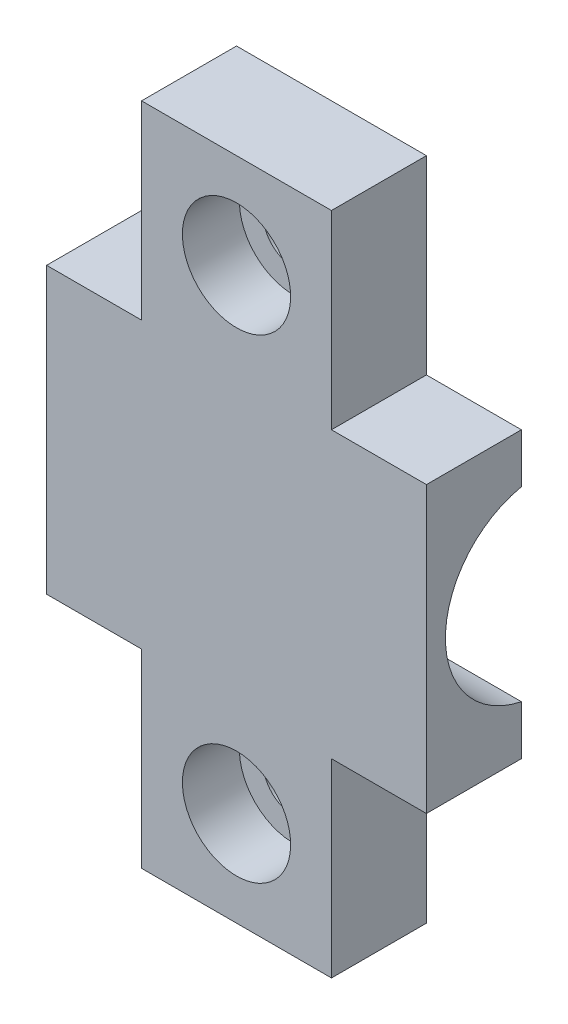
from build123d import *

# Parameters (mm, degrees)
BOSS_EXTRUDE1_DEPTH     = 20
CUT_EXTRUDE1_DEPTH      = 28.041634566
CUT_EXTRUDE1_DEPTH_BACK = 28.041634566
SKETCH2_W               = 5
SKETCH2_H               = 10
SKETCH2_R               = 1.6
CUT_EXTRUDE2_DEPTH      = 28.041634566
CUT_EXTRUDE2_DEPTH_BACK = 3
SKETCH2_3_R             = 2.85
SKETCH2_3_R_2           = 1.6


with BuildPart() as part:
    # Sketch1 → Boss-Extrude1 (new body)
    with BuildSketch(Plane.YZ):
        with BuildLine():
            Line((4.898979486, 1), (17.5, 1))
            Line((17.5, 1), (17.5, 6))
            Line((17.5, 6), (-17.5, 6))
            Line((-17.5, 6), (-17.5, 1))
            Line((-17.5, 1), (-4.898979486, 1))
            ThreePointArc((-4.898979486, 1), (0, 5), (4.898979486, 1))
        make_face()
    extrude(amount=BOSS_EXTRUDE1_DEPTH)

    # Sketch2 → Cut-Extrude1 (cut, two sides: drawn at the far end of the back side and taken through both)
    with BuildSketch(Plane.XY.offset(6).offset(-CUT_EXTRUDE1_DEPTH_BACK)):
        with Locations((2.5, 12.5)):
            Rectangle(SKETCH2_W, SKETCH2_H)
        with Locations((17.5, 12.5)):
            Rectangle(SKETCH2_W, SKETCH2_H)
        with Locations((2.5, -12.5)):
            Rectangle(SKETCH2_W, SKETCH2_H)
        with Locations((17.5, -12.5)):
            Rectangle(SKETCH2_W, SKETCH2_H)
        with Locations((10, -12.5)):
            Circle(SKETCH2_R)
        with Locations((10, 12.5)):
            Circle(SKETCH2_R)
    extrude(amount=CUT_EXTRUDE1_DEPTH + CUT_EXTRUDE1_DEPTH_BACK, mode=Mode.SUBTRACT)

    # Sketch2_3 → Cut-Extrude2 (cut, two sides: drawn at the far end of the back side and taken through both)
    # profile 1 of 2: a face of its own
    with BuildSketch(Plane.XY.offset(6).offset(-CUT_EXTRUDE2_DEPTH_BACK)):
        with Locations((10, -12.5)):
            Circle(SKETCH2_3_R)
        with Locations((10, -12.5)):
            Circle(SKETCH2_3_R_2, mode=Mode.SUBTRACT)
    # profile 2 of 2: a face of its own
    with BuildSketch(Plane.XY.offset(6).offset(-CUT_EXTRUDE2_DEPTH_BACK)):
        with Locations((10, 12.5)):
            Circle(SKETCH2_3_R)
        with Locations((10, 12.5)):
            Circle(SKETCH2_3_R_2, mode=Mode.SUBTRACT)
    extrude(amount=CUT_EXTRUDE2_DEPTH + CUT_EXTRUDE2_DEPTH_BACK, mode=Mode.SUBTRACT)


solid = part.part
